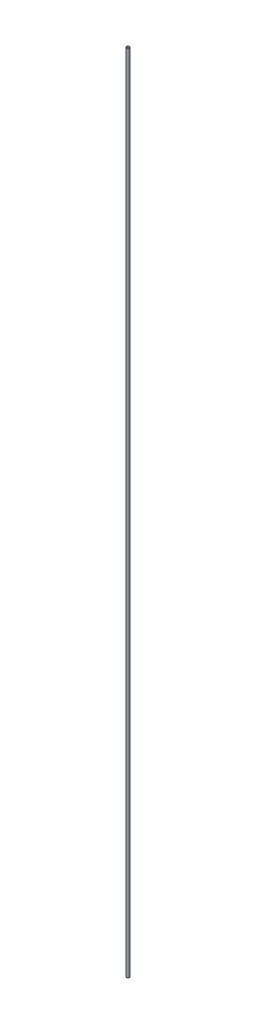
from build123d import *

# Parameters (mm, degrees)
SKETCH1_R   = 3.175
SKETCH1_R_2 = 3.026957157


with BuildPart() as part:
    # Sweep1: sweep along a path in Sketch2
    with BuildLine(Plane(origin=(0, 0, 0), x_dir=(0, 0, -1), z_dir=(1, 0, 0))) as sweep1_path:
        Line((0, 0), (0, -1828.8))
    # Sketch1 → Sweep1 (sweep)
    with BuildSketch(Plane(origin=(0, 0, 0), x_dir=(1, 0, 0), z_dir=(0, 1, 0))):
        Circle(SKETCH1_R)
        Circle(SKETCH1_R_2, mode=Mode.SUBTRACT)
    sweep(path=sweep1_path.line)


solid = part.part
